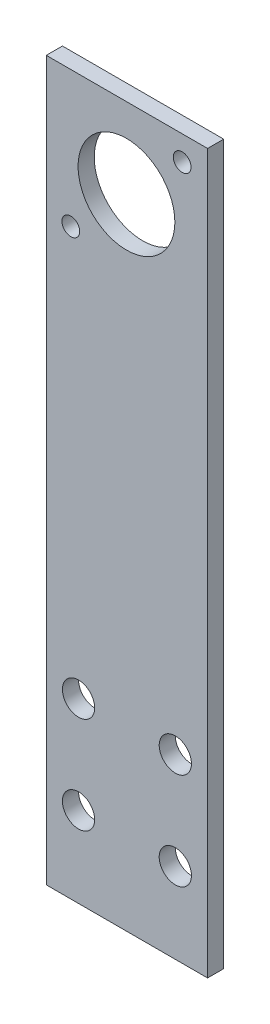
from build123d import *

# Parameters (mm, degrees)
SKETCH1_W           = 31.75
SKETCH1_H           = 147.32
BOSS_EXTRUDE1_DEPTH = 3.175
CUT_EXTRUDE4_REACH  = 5.175
SKETCH5_W           = 31.75
SKETCH5_H           = 5.842
CUT_EXTRUDE5_REACH  = 5.175
SKETCH6_W           = 31.75
SKETCH6_H           = 0.0635
CUT_EXTRUDE6_REACH  = 5.175
SKETCH8_R           = 3.175
SKETCH10_R          = 9.525
CUT_EXTRUDE7_DEPTH  = 4.175


with BuildPart() as part:
    # Sketch1 → Boss-Extrude1 (new body)
    with BuildSketch(Plane.XY):
        with Locations((15.875, 73.66)):
            Rectangle(SKETCH1_W, SKETCH1_H)
    extrude(amount=BOSS_EXTRUDE1_DEPTH)

    # Sketch5 → Cut-Extrude4 (cut, up to next)
    with BuildSketch(Plane.XY.offset(3.175), mode=Mode.PRIVATE) as cut_extrude4_sk1:
        with Locations((15.875, 2.921)):
            Rectangle(SKETCH5_W, SKETCH5_H)
    cut_extrude4_tool1 = extrude(cut_extrude4_sk1.sketch, amount=-CUT_EXTRUDE4_REACH, mode=Mode.PRIVATE) & part.part
    add(cut_extrude4_tool1.solids().sort_by_distance((15.875, 2.921, 3.175))[0], mode=Mode.SUBTRACT)

    # Sketch6 → Cut-Extrude5 (cut, up to next)
    with BuildSketch(Plane.XY.offset(3.175), mode=Mode.PRIVATE) as cut_extrude5_sk1:
        with Locations((15.875, 5.87375)):
            Rectangle(SKETCH6_W, SKETCH6_H)
    cut_extrude5_tool1 = extrude(cut_extrude5_sk1.sketch, amount=-CUT_EXTRUDE5_REACH, mode=Mode.PRIVATE) & part.part
    add(cut_extrude5_tool1.solids().sort_by_distance((15.875, 5.87375, 3.175))[0], mode=Mode.SUBTRACT)

    # Sketch8 → Cut-Extrude6 (cut, up to next)
    with BuildSketch(Plane.XY.offset(3.175), mode=Mode.PRIVATE) as cut_extrude6_sk1:
        with Locations((25.4, 40.8305)):
            Circle(SKETCH8_R)
    cut_extrude6_tool1 = extrude(cut_extrude6_sk1.sketch, amount=-CUT_EXTRUDE6_REACH, mode=Mode.PRIVATE) & part.part
    add(cut_extrude6_tool1.solids().sort_by_distance((25.4, 40.8305, 3.175))[0], mode=Mode.SUBTRACT)
    # Sketch8 → Cut-Extrude6 (cut, up to next)
    with BuildSketch(Plane.XY.offset(3.175), mode=Mode.PRIVATE) as cut_extrude6_sk2:
        with Locations((6.35, 40.8305)):
            Circle(SKETCH8_R)
    cut_extrude6_tool2 = extrude(cut_extrude6_sk2.sketch, amount=-CUT_EXTRUDE6_REACH, mode=Mode.PRIVATE) & part.part
    add(cut_extrude6_tool2.solids().sort_by_distance((6.35, 40.8305, 3.175))[0], mode=Mode.SUBTRACT)
    # Sketch8 → Cut-Extrude6 (cut, up to next)
    with BuildSketch(Plane.XY.offset(3.175), mode=Mode.PRIVATE) as cut_extrude6_sk3:
        with Locations((6.35, 21.7805)):
            Circle(SKETCH8_R)
    cut_extrude6_tool3 = extrude(cut_extrude6_sk3.sketch, amount=-CUT_EXTRUDE6_REACH, mode=Mode.PRIVATE) & part.part
    add(cut_extrude6_tool3.solids().sort_by_distance((6.35, 21.7805, 3.175))[0], mode=Mode.SUBTRACT)
    # Sketch8 → Cut-Extrude6 (cut, up to next)
    with BuildSketch(Plane.XY.offset(3.175), mode=Mode.PRIVATE) as cut_extrude6_sk4:
        with Locations((25.4, 21.7805)):
            Circle(SKETCH8_R)
    cut_extrude6_tool4 = extrude(cut_extrude6_sk4.sketch, amount=-CUT_EXTRUDE6_REACH, mode=Mode.PRIVATE) & part.part
    add(cut_extrude6_tool4.solids().sort_by_distance((25.4, 21.7805, 3.175))[0], mode=Mode.SUBTRACT)

    # Sketch10 → Cut-Extrude7 (cut, through all)
    with BuildSketch(Plane.XY.offset(3.175)):
        with Locations((15.7861, 131.5339)):
            Circle(SKETCH10_R)
        with BuildLine():
            ThreePointArc((6.5786, 120.5738), (4.826, 122.3264), (3.0734, 120.5738))
            ThreePointArc((3.0734, 120.5738), (4.826, 118.8212), (6.5786, 120.5738))
        make_face()
        with BuildLine():
            ThreePointArc((24.9936, 142.494), (26.7462, 140.7414), (28.4988, 142.494))
            ThreePointArc((28.4988, 142.494), (26.7462, 144.2466), (24.9936, 142.494))
        make_face()
    extrude(amount=-CUT_EXTRUDE7_DEPTH, mode=Mode.SUBTRACT)


solid = part.part
